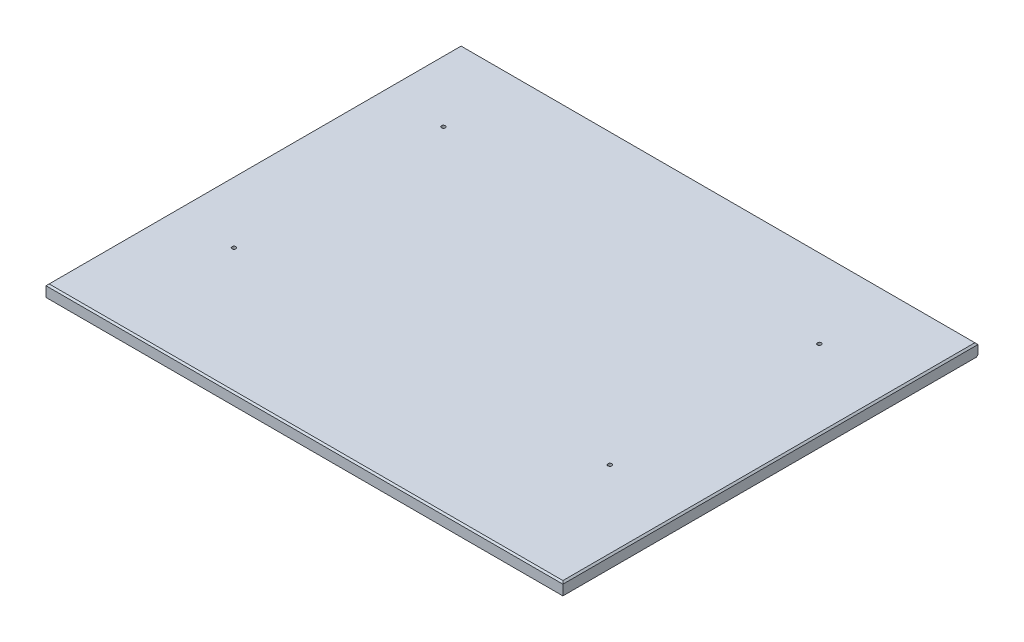
from build123d import *

# Parameters (mm, degrees)
SKETCH1_W           = 838.2
SKETCH1_H           = 673.1
BOSS_EXTRUDE1_DEPTH = 19.05
CHAMFER1_SIZE       = 2.54
CHAMFER2_SIZE       = 2.54
SKETCH2_R           = 3.175
CUT_EXTRUDE1_DEPTH  = 20.05


with BuildPart() as part:
    # Sketch1 → Boss-Extrude1 (new body)
    with BuildSketch(Plane(origin=(0, 0, 0), x_dir=(1, 0, 0), z_dir=(0, 1, 0))):
        with Locations((419.1, 336.55)):
            Rectangle(SKETCH1_W, SKETCH1_H)
    extrude(amount=BOSS_EXTRUDE1_DEPTH)

    # Chamfer1
    chamfer1_edges = [part.edges().sort_by_distance(p)[0] for p in [
        (838.2, 19.05, -336.55),
        (419.1, 19.05, -673.1),
        (0, 19.05, -336.55),
        (419.1, 19.05, 0),
    ]]
    chamfer(chamfer1_edges, length=CHAMFER1_SIZE)

    # Chamfer2
    chamfer2_edges = [part.edges().sort_by_distance(p)[0] for p in [
        (419.1, 0, -673.1),
    ]]
    chamfer(chamfer2_edges, length=CHAMFER2_SIZE)

    # Sketch2 → Cut-Extrude1 (cut, through all)
    with BuildSketch(Plane(origin=(0, 19.05, 0), x_dir=(1, 0, 0), z_dir=(0, 1, 0))):
        with Locations((101.6, 542.925)):
            Circle(SKETCH2_R)
        with Locations((101.6, 203.2)):
            Circle(SKETCH2_R)
        with Locations((711.2, 542.925)):
            Circle(SKETCH2_R)
        with Locations((711.2, 203.2)):
            Circle(SKETCH2_R)
    extrude(amount=-CUT_EXTRUDE1_DEPTH, mode=Mode.SUBTRACT)


solid = part.part
